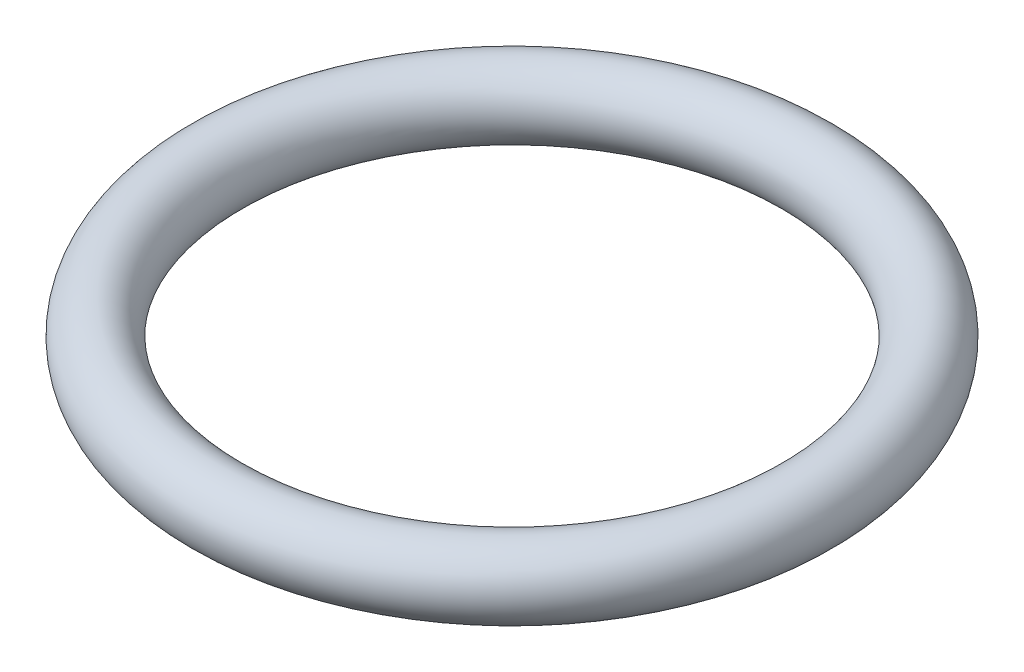
from build123d import *

# Parameters (mm, degrees)
SKIZZE1_ONE_SIDE_R   = 52.5
SKIZZE1_ONE_SIDE_R_2 = 42.5


with BuildPart() as part:
    # Skizze1 one side → Rotation-Dünn1 (revolve)
    with BuildSketch(Plane.XY):
        with Locations((-442.5, 0)):
            Circle(SKIZZE1_ONE_SIDE_R)
        with Locations((-442.5, 0)):
            Circle(SKIZZE1_ONE_SIDE_R_2, mode=Mode.SUBTRACT)
    revolve(axis=Axis((0, 0, 0), (0, 1, 0)))


solid = part.part
